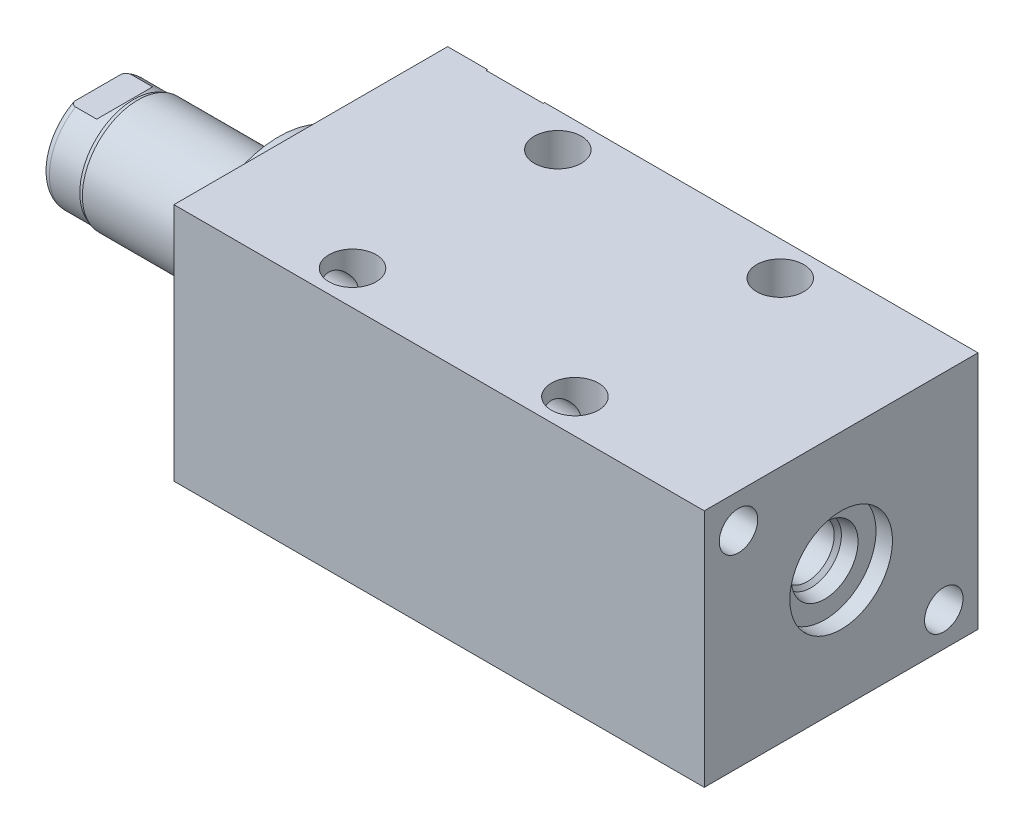
from build123d import *

# Parameters (mm, degrees)
SKETCH1_W          = 50.8
SKETCH1_H          = 44.45
EXTRUDE1_DEPTH     = 98.425
SKETCH5_R          = 17.4625
EXTRUDE2_DEPTH     = 5.969
SKETCH6_W          = 10.31875
SKETCH6_H          = 33.528
CUT_EXTRUDE4_DEPTH = 30.48
HOLE1_D            = 7.1374
HOLE1_DEPTH        = 98.425
HOLE2_D            = 8.7376
HOLE2_DEPTH        = 44.45
LPATTERN1_COUNT    = 2
LPATTERN1_PITCH    = 41.275


with BuildPart() as part:
    # Sketch1 → Extrude1 (new body)
    with BuildSketch(Plane(origin=(0, 0, 0), x_dir=(0, 0, -1), z_dir=(1, 0, 0))):
        Rectangle(SKETCH1_W, SKETCH1_H)
    extrude(amount=EXTRUDE1_DEPTH)

    # S2D0002 → Cut-Revolve1 (revolve, cut)
    with BuildSketch(Plane(origin=(0, 14.3002, 0), x_dir=(-1, 0, 0), z_dir=(0, 1, 0)), mode=Mode.PRIVATE) as cut_revolve1_sk:
        Polygon((-18.8849, -25.146), (-22.225, -25.146), (-22.225, -25.4), (-12.7, -25.4), (-12.7, -11.176), (-17.6784, -11.176), (-17.6784, -21.929393135), (-18.342306865, -22.5933), align=None)
    revolve(cut_revolve1_sk.sketch.rotate(Axis((12.7, 14.3002, -19.13842003), (0, 0, 1)), 180), axis=Axis((12.7, 14.3002, -19.13842003), (0, 0, 1)), mode=Mode.SUBTRACT)  # turned: the seam where the file's is

    # Sketch3 → Cut-Revolve2 (revolve, cut)
    with BuildSketch(Plane(origin=(41.148, 0, -25.146), x_dir=(1, 0, 0), z_dir=(0, 1, 0))):
        Polygon((47.5869, 0), (50.927, 0), (50.927, 0.254), (41.402, 0.254), (41.402, -13.97), (46.3804, -13.97), (46.3804, -3.216606865), (47.044306865, -2.5527), align=None)
    revolve(axis=Axis((82.55, 0, -3.189624441), (0, 0, -1)), mode=Mode.SUBTRACT)

    # Sketch4 → Cut-Revolve3 (revolve, cut)
    with BuildSketch(Plane(origin=(53.975, 0, 0), x_dir=(0, -1, 0), z_dir=(0, 0, 1)), mode=Mode.PRIVATE) as cut_revolve3_sk:
        Polygon((6.1849, 41.402), (9.525, 41.402), (9.525, 44.45), (0, 44.45), (0, 30.0482), (4.9784, 30.0482), (4.9784, 38.185393135), (5.642306865, 38.8493), align=None)
    revolve(cut_revolve3_sk.sketch.rotate(Axis((38.879609832, 0, 0), (1, 0, 0)), 270), axis=Axis((38.879609832, 0, 0), (1, 0, 0)), mode=Mode.SUBTRACT)  # turned: the seam where the file's is

    # Sketch5 → Extrude2 (add)
    with BuildSketch(Plane.ZY):
        Circle(SKETCH5_R)
    extrude(amount=EXTRUDE2_DEPTH)

    # Sketch6 → Revolve1 (revolve)
    with BuildSketch(Plane(origin=(0, 0, 0), x_dir=(0, 0, 1), z_dir=(0, -1, 0)), mode=Mode.PRIVATE) as revolve1_sk:
        with Locations((-5.159375, 22.733)):
            Rectangle(SKETCH6_W, SKETCH6_H)
    revolve(revolve1_sk.sketch.rotate(Axis((5.754582971, 0, 0), (-1, 0, 0)), 180), axis=Axis((5.754582971, 0, 0), (-1, 0, 0)))  # turned: the seam where the file's is

    # S2D0001 → Cut-Revolve4 (revolve, cut)
    with BuildSketch(Plane(origin=(-18.511260017, 3.2639, 0), x_dir=(0, 1, 0), z_dir=(0, 0, 1)), mode=Mode.PRIVATE) as cut_revolve4_sk:
        Polygon((0, 19.05), (0, 5.923539983), (-3.2639, 5.923539983), (-3.2639, 20.985739983), (1.1176, 20.985739983), align=None)
    revolve(cut_revolve4_sk.sketch.rotate(Axis((0, 0, 0), (-1, 0, 0)), 270), axis=Axis((0, 0, 0), (-1, 0, 0)), mode=Mode.SUBTRACT)  # turned: the seam where the file's is

    # Sketch8 → Cut-Revolve5 (revolve, cut)
    with BuildSketch(Plane(origin=(0, 0, 0), x_dir=(0, 0, -1), z_dir=(0, 1, 0)), mode=Mode.PRIVATE) as cut_revolve5_sk:
        with BuildLine():
            Line((-10.31875, 32.0802), (-10.033, 32.8422))
            Line((-10.033, 32.8422), (-10.033, 38.481))
            ThreePointArc((-10.033, 38.481), (-9.932678675, 39.024796865), (-9.644922533, 39.497))
            Line((-9.644922533, 39.497), (-10.31875, 39.497))
            Line((-10.31875, 39.497), (-10.31875, 32.0802))
        make_face()
    revolve(cut_revolve5_sk.sketch.rotate(Axis((-12.65936, 0, 0), (-1, 0, 0)), 180), axis=Axis((-12.65936, 0, 0), (-1, 0, 0)), mode=Mode.SUBTRACT)  # turned: the seam where the file's is

    # Sketch12 → Cut-Extrude4 (cut, symmetric)
    with BuildSketch(Plane(origin=(0, 0, 0), x_dir=(0, -1, 0), z_dir=(0, 0, -1))):
        Polygon((8.5852, 39.497), (8.5852, 34.544), (10.033, 33.0962), (10.033, 39.497), align=None)
        Polygon((-8.5852, 39.497), (-8.5852, 34.544), (-10.033, 33.0962), (-10.033, 39.497), align=None)
    extrude(amount=CUT_EXTRUDE4_DEPTH, both=True, mode=Mode.SUBTRACT)

    # Hole1
    with Locations(Plane.ZY):
        with Locations((-19.05, -15.875), (19.05, 15.875)):
            Hole(HOLE1_D / 2, depth=HOLE1_DEPTH)

    # Hole2
    with Locations(Plane(origin=(0, 22.225, 0), x_dir=(-1, 0, 0), z_dir=(0, 1, 0))):
        with Locations((-26.797, -19.05), (-26.797, 19.05)):
            hole2 = Hole(HOLE2_D / 2, depth=HOLE2_DEPTH)

    # LPattern1: Hole2 ×2
    with Locations(*[(i * LPATTERN1_PITCH, 0, 0) for i in range(1, LPATTERN1_COUNT)]):
        add(hole2, mode=Mode.SUBTRACT)


solid = part.part
